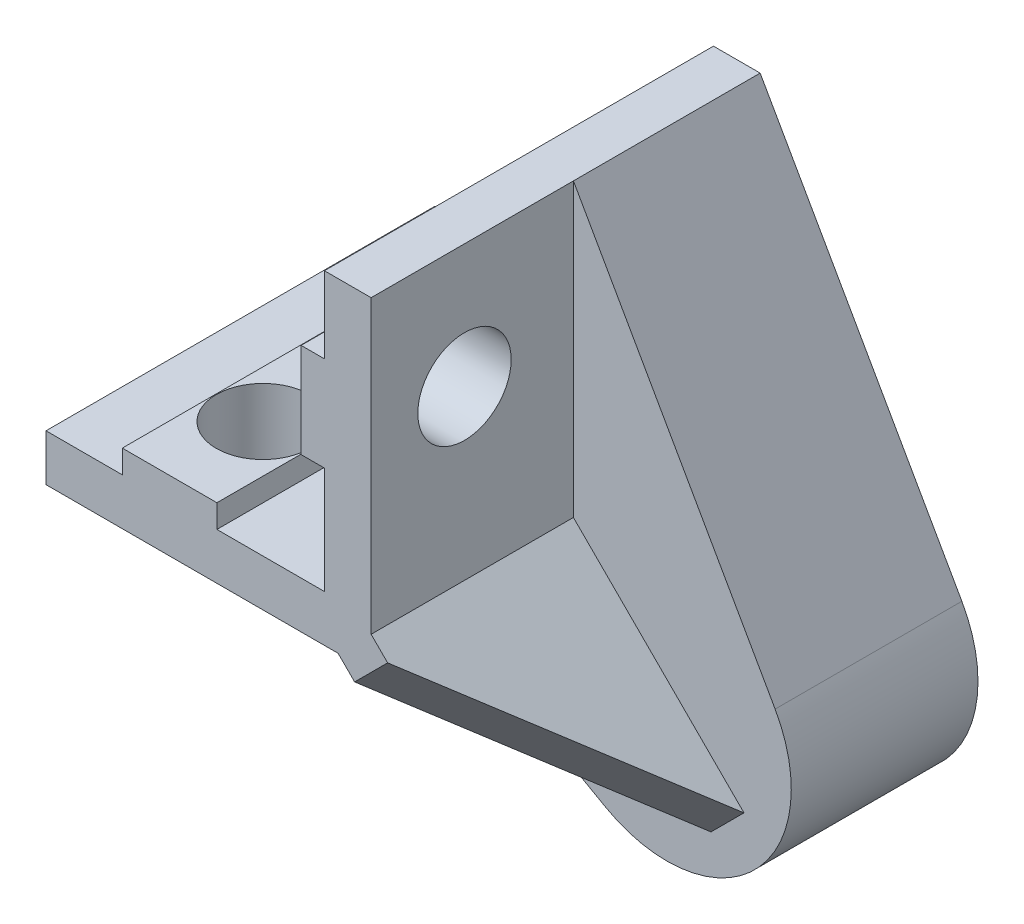
from build123d import *

# Parameters (mm, degrees)
BOSS_EXTRUDE1_DEPTH = 25
SKETCH2_R           = 3
CUT_EXTRUDE1_DEPTH  = 15
SKETCH3_R           = 3
CUT_EXTRUDE2_DEPTH  = 15
BOSS_EXTRUDE2_DEPTH = 12
BOSS_EXTRUDE4_DEPTH = 1.5
SKETCH6_R           = 4.85
CUT_EXTRUDE3_DEPTH  = 9


with BuildPart() as part:
    # Sketch1 → Boss-Extrude1 (new body)
    with BuildSketch(Plane.XY):
        Polygon((227.088719843, 62.282971172), (227.088719843, 57.379571172), (225.590119843, 57.379571172), (225.590119843, 51.299571172), (227.088719843, 51.299571172), (227.088719843, 44.429550862), (220.178702595, 44.429550862), (220.178702595, 45.917195068), (214.098687419, 45.917195068), (214.098687419, 44.429550862), (209.19527518, 44.429550862), (209.19527518, 41.429550862), (230.088719843, 41.429550862), (230.088719843, 62.282971172), align=None)
    extrude(amount=-BOSS_EXTRUDE1_DEPTH)

    # Sketch2 → Cut-Extrude1 (cut)
    with BuildSketch(Plane(origin=(230.088719843, 0, 0), x_dir=(0, 0, -1), z_dir=(1, 0, 0))):
        with Locations((6, 54.339571172)):
            Circle(SKETCH2_R)
    extrude(amount=-CUT_EXTRUDE1_DEPTH, mode=Mode.SUBTRACT)

    # Sketch3 → Cut-Extrude2 (cut)
    with BuildSketch(Plane.XZ.offset(-41.429550862)):
        with Locations((217.138695007, -6)):
            Circle(SKETCH3_R)
    extrude(amount=-CUT_EXTRUDE2_DEPTH, mode=Mode.SUBTRACT)

    # Sketch4 → Boss-Extrude2 (add)
    with BuildSketch(Plane(origin=(0, 0, -25), x_dir=(-1, 0, 0), z_dir=(0, 0, -1))):
        with BuildLine():
            Line((-230.088719843, 62.282971172), (-243.051733392, 39.368642422))
            ThreePointArc((-243.051733392, 39.368642422), (-241.747687926, 29.774811236), (-232.154834185, 28.463594817))
            Line((-232.154834185, 28.463594817), (-209.19527518, 41.429550862))
            Line((-209.19527518, 41.429550862), (-230.088719843, 41.429550862))
            Line((-230.088719843, 41.429550862), (-230.088719843, 62.282971172))
        make_face()
    extrude(amount=-BOSS_EXTRUDE2_DEPTH)

    # Sketch5 → Boss-Extrude4 (add, symmetric)
    with BuildSketch(Plane(origin=(135.717402312, 135.766641949, 0), x_dir=(0.707235019, -0.70697852, 0), z_dir=(-0.70697852, -0.707235019, 0))):
        Polygon((133.436997596, -13), (147.436997596, -13), (133.436997596, 0), (129.194356979, 0), (129.194356979, -13), align=None)
    extrude(amount=BOSS_EXTRUDE4_DEPTH, both=True)

    # Sketch6 → Cut-Extrude3 (cut)
    with BuildSketch(Plane(origin=(0, 0, -25), x_dir=(-1, 0, 0), z_dir=(0, 0, -1))):
        with Locations((-236.088719843, 35.429550862)):
            Circle(SKETCH6_R)
    extrude(amount=-CUT_EXTRUDE3_DEPTH, mode=Mode.SUBTRACT)


solid = part.part
